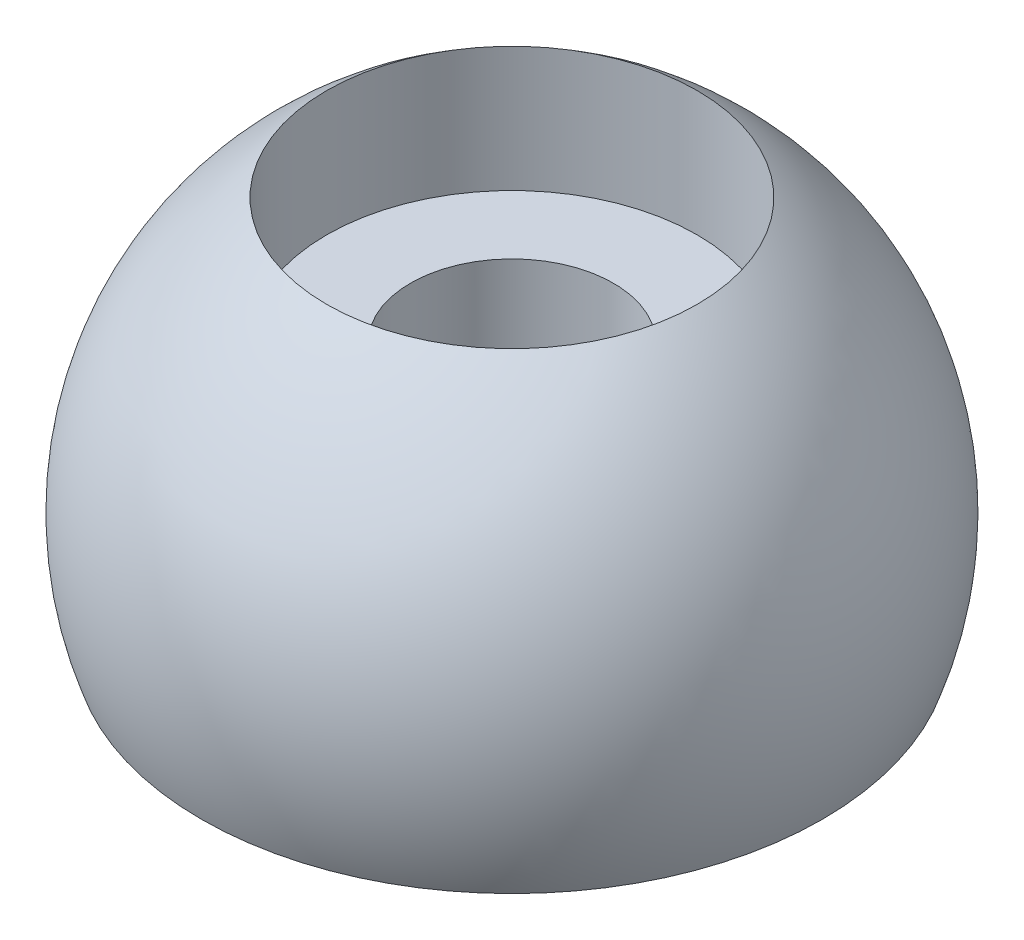
from build123d import *

# Parameters (mm, degrees)
TRUNCATED_BALL_DEPTH      = 11.998522628
TRUNCATED_BALL_DEPTH_BACK = 11.998522628
SKETCH3_R                 = 4.1275
RECESSED_DEPTH            = 0.127
CUT_EXTRUDE1_DEPTH        = 0.127


with BuildPart() as part:
    # Sketch1 → Complete_Ball (revolve)
    with BuildSketch(Plane.XY):
        with BuildLine():
            Line((0, 6.35), (0, -6.35))
            ThreePointArc((0, -6.35), (6.35, 0), (0, 6.35))
        make_face()
    revolve(axis=Axis((0, 5.621617492, 0), (0, -1, 0)))

    # Sketch2 → Truncated_ball (cut, two sides)
    with BuildSketch(Plane.XY) as truncated_ball_sk:
        with BuildLine():
            Line((-5.980823609, -2.1336), (5.980823609, -2.1336))
            ThreePointArc((5.980823609, -2.1336), (0, -6.35), (-5.980823609, -2.1336))
        make_face()
    extrude(amount=TRUNCATED_BALL_DEPTH, mode=Mode.SUBTRACT)
    extrude(truncated_ball_sk.sketch, amount=-TRUNCATED_BALL_DEPTH_BACK, mode=Mode.SUBTRACT)

    # Sketch3 → Recessed (cut)
    with BuildSketch(Plane.XZ.offset(2.1336)):
        with Locations(Location((0, 0, 0), (0, 0, 270))):
            Circle(SKETCH3_R)
    extrude(amount=-RECESSED_DEPTH, mode=Mode.SUBTRACT)

    # Sketch5 → Counterbored_hole (revolve, cut)
    with BuildSketch(Plane.XY, mode=Mode.PRIVATE) as counterbored_hole_sk:
        Polygon((1.9558, -2.1336), (1.9558, 2.8448), (3.5687, 2.8448), (3.5687, 6.35), (0, 6.35), (0, -2.1336), align=None)
    revolve(counterbored_hole_sk.sketch.rotate(Axis((0, 7.818373071, 0), (0, -1, 0)), 90), axis=Axis((0, 7.818373071, 0), (0, -1, 0)), mode=Mode.SUBTRACT)

    # Sketch9 → Cut-Extrude1 (cut)
    with BuildSketch(Plane.XZ.offset(2.0066)):
        with BuildLine():
            Line((-0.266710017, -2.9083), (-0.266710017, -2.137804395))
            Line((-0.266710017, -2.137804395), (0.021762797, -2.137804395))
            add(Edge.make_bspline(
                [(0.021762797, -2.137804395), (0.028916445, -2.137831838), (0.042875247, -2.137885387), (0.063257985, -2.1392246), (0.08256196, -2.141056366), (0.100828728, -2.143417569), (0.117979251, -2.146843626), (0.133997544, -2.150994066), (0.148966969, -2.155781463), (0.167264808, -2.16307422), (0.188351063, -2.174299324), (0.210936444, -2.19104895), (0.230586604, -2.211159242), (0.246755795, -2.234216831), (0.260077465, -2.258846684), (0.269522373, -2.28457958), (0.275561015, -2.31085525), (0.276246169, -2.328647268), (0.276588166, -2.337528215)],
                knots=[0, 0, 0, 0, 0.939712594, 1.833646414, 2.682508961, 3.487467313, 4.25240329, 4.978730417, 5.660668875, 6.315918528, 7.564895217, 8.787077865, 9.996481721, 11.241996224, 12.475862915, 13.665015424, 14.834484263, 16, 16, 16, 16], degree=3))
            add(Edge.make_bspline(
                [(0.276588166, -2.337528215), (0.276228655, -2.345790733), (0.275513098, -2.362236109), (0.269818069, -2.386461149), (0.260829571, -2.409983511), (0.24811958, -2.432517235), (0.231874618, -2.453650072), (0.211735504, -2.472667007), (0.187991636, -2.489608795), (0.170171864, -2.498639265), (0.160982956, -2.5032959)],
                knots=[0, 0, 0, 0, 0.926741525, 1.844548388, 2.778836836, 3.746021974, 4.738420572, 5.759761325, 6.844803049, 8, 8, 8, 8], degree=3))
            add(Edge.make_bspline(
                [(0.160982956, -2.5032959), (0.166667275, -2.505075335), (0.177796205, -2.508559168), (0.193795198, -2.514934092), (0.208813366, -2.522192856), (0.2228834, -2.530347388), (0.23591023, -2.539473202), (0.2478571, -2.549584525), (0.258806843, -2.560524888), (0.268739897, -2.572287634), (0.277465043, -2.58479707), (0.285290409, -2.597779786), (0.291752256, -2.611392125), (0.297048797, -2.625598745), (0.301180886, -2.640311862), (0.304148175, -2.655588064), (0.305839455, -2.671391794), (0.306093479, -2.68212759), (0.306222612, -2.687585113)],
                knots=[0, 0, 0, 0, 1.127427615, 2.20731145, 3.257257018, 4.283066884, 5.282973838, 6.264540225, 7.242620376, 8.210460609, 9.17525685, 10.12748095, 11.077310519, 12.023587065, 12.994999128, 13.967387486, 14.966724908, 16, 16, 16, 16], degree=3))
            add(Edge.make_bspline(
                [(0.306222612, -2.687585113), (0.30595645, -2.69634709), (0.305428882, -2.713714396), (0.301191929, -2.739276148), (0.294031702, -2.7638644), (0.28417626, -2.787081588), (0.272433103, -2.808549297), (0.259086593, -2.827705432), (0.244477096, -2.844352877), (0.22819322, -2.858356354), (0.210340006, -2.870241208), (0.190413202, -2.880249032), (0.168566879, -2.889074974), (0.144357023, -2.896125462), (0.117794653, -2.901726361), (0.088519295, -2.905365274), (0.056485971, -2.907970248), (0.034167963, -2.908187011), (0.022534527, -2.9083)],
                knots=[0, 0, 0, 0, 1.028073207, 2.037766189, 3.031549473, 4.027532207, 4.992436545, 5.898794514, 6.762903869, 7.584966804, 8.412380356, 9.273953678, 10.198004568, 11.174406109, 12.229717296, 13.381036288, 14.634844708, 16, 16, 16, 16], degree=3))
            Line((0.022534527, -2.9083), (-0.266710017, -2.9083))
        make_face()
        with BuildLine():
            Line((-0.158050381, -2.463783305), (0.00077173, -2.463783305))
            add(Edge.make_bspline(
                [(0.00077173, -2.463783305), (0.005968785, -2.463762743), (0.015953502, -2.46372324), (0.030356217, -2.463172446), (0.043649233, -2.46270254), (0.055781131, -2.461523111), (0.066812012, -2.460367914), (0.076697733, -2.458812838), (0.085486714, -2.45706062), (0.090868209, -2.455435306), (0.093379375, -2.454676886)],
                knots=[0, 0, 0, 0, 1.335841395, 2.566453063, 3.705076039, 4.753984432, 5.69893722, 6.555639608, 7.326018133, 8, 8, 8, 8], degree=3))
            add(Edge.make_bspline(
                [(0.093379375, -2.454676886), (0.099279717, -2.452609996), (0.11065434, -2.448625465), (0.125897399, -2.439576193), (0.138880055, -2.428717112), (0.149567516, -2.415856475), (0.157780301, -2.401063109), (0.163869844, -2.384643791), (0.167204004, -2.366368995), (0.167680456, -2.353696066), (0.167928529, -2.347097672)],
                knots=[0, 0, 0, 0, 1.059015028, 2.041559358, 2.989777133, 3.920090524, 4.862499371, 5.848878527, 6.879979022, 8, 8, 8, 8], degree=3))
            add(Edge.make_bspline(
                [(0.167928529, -2.347097672), (0.167729061, -2.340756189), (0.167340322, -2.328397369), (0.164077197, -2.31045022), (0.158430481, -2.293753694), (0.150783282, -2.278311452), (0.141099895, -2.264573361), (0.129542435, -2.252761818), (0.115697414, -2.243832811), (0.102756467, -2.238262878), (0.09111711, -2.23477836), (0.080717754, -2.232716714), (0.068921782, -2.230900199), (0.055690377, -2.229355858), (0.041018534, -2.228157307), (0.024861047, -2.227205138), (0.007256378, -2.22680087), (-0.00493898, -2.226739552), (-0.011267263, -2.226707734)],
                knots=[0, 0, 0, 0, 1.216168307, 2.37017178, 3.484610845, 4.588286376, 5.664695412, 6.69777344, 7.738183022, 8.803673002, 9.390844981, 10.0665252, 10.835811589, 11.680682236, 12.621801058, 13.660007223, 14.785756265, 16, 16, 16, 16], degree=3))
            Line((-0.011267263, -2.226707734), (-0.158050381, -2.226707734))
            Line((-0.158050381, -2.226707734), (-0.158050381, -2.463783305))
        make_face(mode=Mode.SUBTRACT)
        with BuildLine():
            Line((-0.158050381, -2.819396661), (0.024232334, -2.819396661))
            add(Edge.make_bspline(
                [(0.024232334, -2.819396661), (0.031486765, -2.819313318), (0.044815157, -2.819160193), (0.063045794, -2.818679835), (0.077781785, -2.817506499), (0.086386824, -2.816243115), (0.090138108, -2.815692355)],
                knots=[0, 0, 0, 0, 1.317581857, 2.420761387, 3.311546315, 4, 4, 4, 4], degree=3))
            add(Edge.make_bspline(
                [(0.090138108, -2.815692355), (0.095516334, -2.814561906), (0.105929971, -2.812373065), (0.120610701, -2.807487801), (0.134071074, -2.80189147), (0.14607616, -2.794779154), (0.157192582, -2.786582698), (0.16685358, -2.776344933), (0.175751817, -2.764713097), (0.183461357, -2.751401785), (0.189695639, -2.736675926), (0.194460394, -2.720763047), (0.19699845, -2.703718942), (0.197372145, -2.692017237), (0.197562976, -2.686041652)],
                knots=[0, 0, 0, 0, 1.067651492, 2.067249321, 3.003744366, 3.895862395, 4.774133402, 5.679610569, 6.621910665, 7.616993802, 8.661192143, 9.724711987, 10.838102842, 12, 12, 12, 12], degree=3))
            add(Edge.make_bspline(
                [(0.197562976, -2.686041652), (0.197350369, -2.679025957), (0.196935765, -2.665344636), (0.192994812, -2.645574434), (0.186485001, -2.627237325), (0.177321084, -2.610587261), (0.166081062, -2.595611962), (0.15248177, -2.582908823), (0.136624895, -2.572828254), (0.118461703, -2.564916959), (0.09723257, -2.559288208), (0.072351402, -2.555469442), (0.043420216, -2.553005284), (0.02274604, -2.552797406), (0.011730302, -2.552686644)],
                knots=[0, 0, 0, 0, 0.96167883, 1.875371887, 2.752872588, 3.621584364, 4.472914353, 5.312011319, 6.159851575, 7.038572308, 8.019870099, 9.164119506, 10.488969081, 12, 12, 12, 12], degree=3))
            Line((0.011730302, -2.552686644), (-0.158050381, -2.552686644))
            Line((-0.158050381, -2.552686644), (-0.158050381, -2.819396661))
        make_face(mode=Mode.SUBTRACT)
    extrude(amount=-CUT_EXTRUDE1_DEPTH, mode=Mode.SUBTRACT)


solid = part.part
